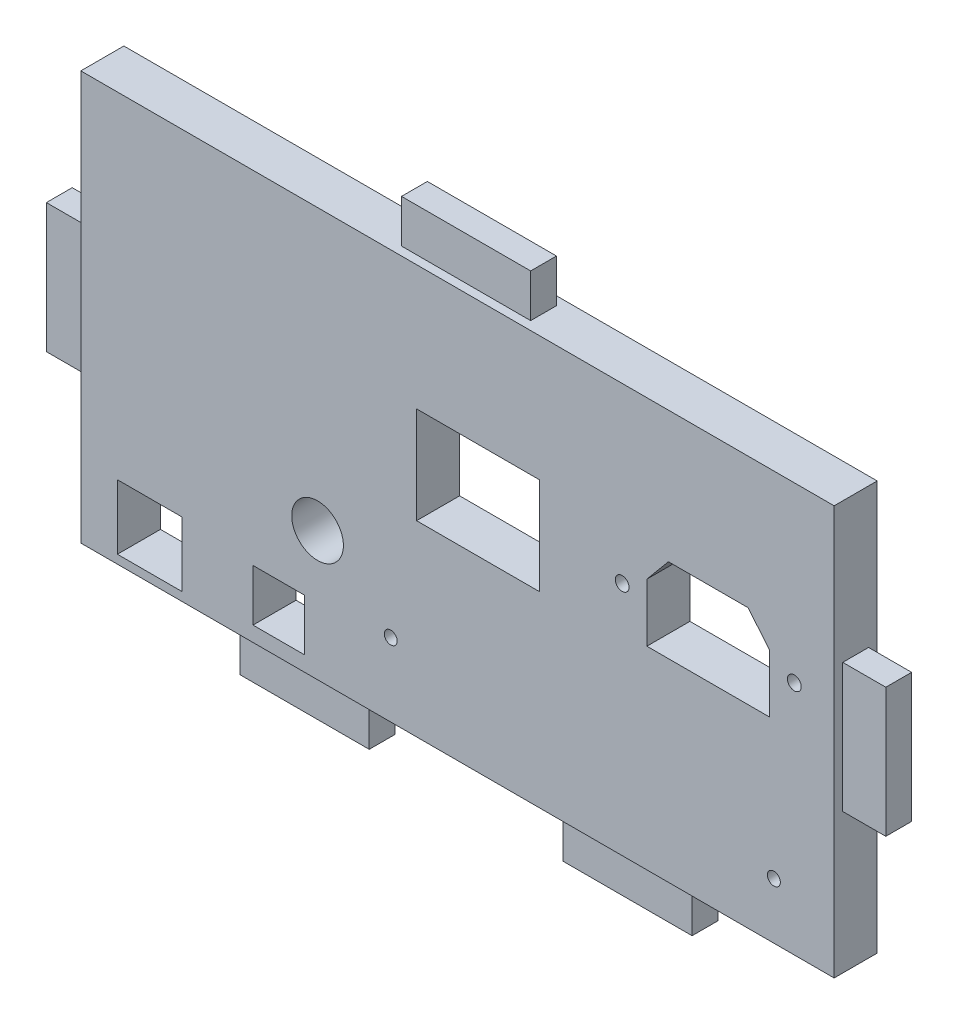
from build123d import *

# Parameters (mm, degrees)
ESBO_O1_W                = 175
ESBO_O1_H                = 95
RESSALTO_EXTRUS_O1_DEPTH = 10
ESBO_O2_W                = 6
ESBO_O2_H                = 30
RESSALTO_EXTRUS_O2_DEPTH = 10
ESBO_O3_W                = 6
ESBO_O3_H                = 30
RESSALTO_EXTRUS_O3_DEPTH = 10
ESBO_O4_W                = 30
ESBO_O4_H                = 6
RESSALTO_EXTRUS_O4_DEPTH = 10
ESBO_O5_W                = 30
ESBO_O5_H                = 6
RESSALTO_EXTRUS_O5_DEPTH = 10
ESBO_O7_R                = 1.5
ESBO_O7_R_2              = 1.6
ESBO_O7_R_3              = 6
ESBO_O7_W                = 28.5
ESBO_O7_H                = 22.5
ESBO_O7_W_2              = 15
ESBO_O7_H_2              = 15
ESBO_O7_W_3              = 12
ESBO_O7_H_3              = 12
CORTE_EXTRUS_O2_DEPTH    = 10


with BuildPart() as part:
    # Esboço1 → Ressalto-extrusão1 (new body)
    with BuildSketch(Plane.XY):
        Rectangle(ESBO_O1_W, ESBO_O1_H)
    extrude(amount=RESSALTO_EXTRUS_O1_DEPTH)

    # Esboço2 → Ressalto-extrusão2 (add)
    with BuildSketch(Plane.ZY.offset(87.5)):
        with Locations((5, 0)):
            Rectangle(ESBO_O2_W, ESBO_O2_H)
    extrude(amount=RESSALTO_EXTRUS_O2_DEPTH)

    # Esboço3 → Ressalto-extrusão3 (add)
    with BuildSketch(Plane(origin=(87.5, 0, 0), x_dir=(0, 0, -1), z_dir=(1, 0, 0))):
        with Locations((-5, 0)):
            Rectangle(ESBO_O3_W, ESBO_O3_H)
    extrude(amount=RESSALTO_EXTRUS_O3_DEPTH)

    # Esboço4 → Ressalto-extrusão4 (add)
    with BuildSketch(Plane.XZ.offset(47.5)):
        with Locations((37.5, 5)):
            Rectangle(ESBO_O4_W, ESBO_O4_H)
        with Locations((-37.5, 5)):
            Rectangle(ESBO_O4_W, ESBO_O4_H)
    extrude(amount=RESSALTO_EXTRUS_O4_DEPTH)

    # Esboço5 → Ressalto-extrusão5 (add)
    with BuildSketch(Plane(origin=(0, 47.5, 0), x_dir=(1, 0, 0), z_dir=(0, 1, 0))):
        with Locations((0, -5)):
            Rectangle(ESBO_O5_W, ESBO_O5_H)
    extrude(amount=RESSALTO_EXTRUS_O5_DEPTH)

    # Esboço7 → Corte-extrusão2 (cut)
    with BuildSketch(Plane.XY.offset(10)):
        with Locations((73.5, -34.5)):
            Circle(ESBO_O7_R)
        with Locations((-15.5, -30.5)):
            Circle(ESBO_O7_R)
        with Locations((78.25, 7.25)):
            Circle(ESBO_O7_R_2)
        with Locations((38.25, 7.25)):
            Circle(ESBO_O7_R_2)
        with Locations((-32.5, -17.5)):
            Circle(ESBO_O7_R_3)
        Polygon((72.5, -2.5), (44, -2.5), (44, 11), (49, 17), (67.5, 17), (72.5, 11), align=None)
        with Locations((4.75, 7.25)):
            Rectangle(ESBO_O7_W, ESBO_O7_H)
        with Locations((-71.5, -38)):
            Rectangle(ESBO_O7_W_2, ESBO_O7_H_2)
        with Locations((-41.5, -38)):
            Rectangle(ESBO_O7_W_3, ESBO_O7_H_3)
    extrude(amount=-CORTE_EXTRUS_O2_DEPTH, mode=Mode.SUBTRACT)


solid = part.part
